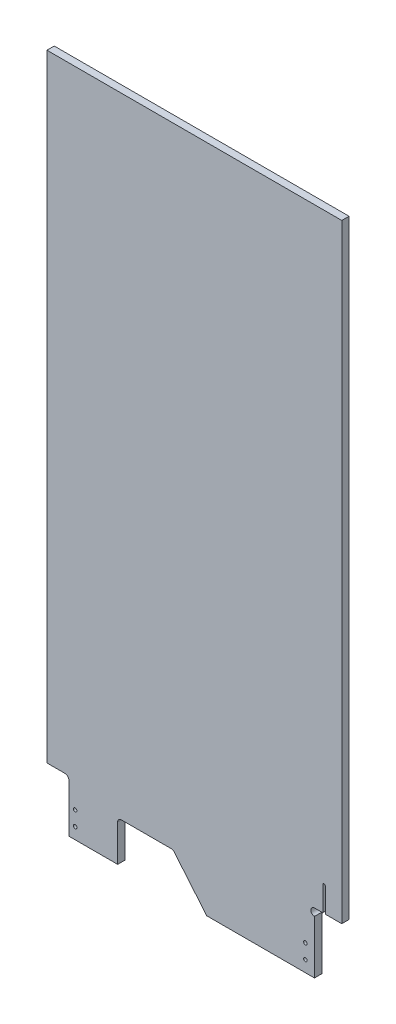
from build123d import *

# Parameters (mm, degrees)
EXTRUDE1_DEPTH     = 12.7
SKETCH3_R          = 3.1115
CUT_EXTRUDE1_DEPTH = 12.7


with BuildPart() as part:
    # Sketch2 → Extrude1 (new body)
    with BuildSketch(Plane.XY):
        with BuildLine():
            Line((10375.902142089, 13017.500110193), (10375.902142089, 13102.653009206))
            ThreePointArc((10375.902142089, 13102.653009206), (10374.042270149, 13107.143137266), (10369.552142089, 13109.003009206))
            Line((10369.552142089, 13109.003009206), (10337.802142089, 13109.003009206))
            Line((10337.802142089, 13109.003009206), (10337.800747814, 14185.900110193))
            Line((10337.800747814, 14185.900110193), (10852.147924282, 14185.900110193))
            Line((10852.147924282, 14185.900110193), (10852.150747814, 13123.290509206))
            Line((10852.150747814, 13123.290509206), (10823.581236416, 13123.290509206))
            Line((10823.581236416, 13123.290509206), (10823.581236416, 13165.835509206))
            ThreePointArc((10823.581236416, 13165.835509206), (10821.295236416, 13168.121509206), (10819.009236416, 13165.835509206))
            Line((10819.009236416, 13165.835509206), (10819.009236416, 13123.290509206))
            Line((10819.009236416, 13123.290509206), (10804.525747814, 13123.290509206))
            ThreePointArc((10804.525747814, 13123.290509206), (10798.175747814, 13116.940509206), (10804.525747814, 13110.590509206))
            Line((10804.525747814, 13110.590509206), (10804.525747814, 13017.500110193))
            Line((10804.525747814, 13017.500110193), (10616.625223517, 13017.500110193))
            Line((10616.625223517, 13017.500110193), (10559.649893716, 13085.667043341))
            ThreePointArc((10559.649893716, 13085.667043341), (10557.466824452, 13087.347190416), (10554.77765388, 13087.944724716))
            Line((10554.77765388, 13087.944724716), (10467.552782059, 13087.944724716))
            ThreePointArc((10467.552782059, 13087.944724716), (10463.062653998, 13086.084852777), (10461.202782059, 13081.594724716))
            Line((10461.202782059, 13081.594724716), (10461.202782059, 13017.500110193))
            Line((10461.202782059, 13017.500110193), (10375.902142089, 13017.500110193))
        make_face()
    extrude(amount=-EXTRUDE1_DEPTH)

    # Sketch3 → Cut-Extrude1 (cut)
    with BuildSketch(Plane.XY):
        with Locations((10387.012550678, 13062.712110193)):
            Circle(SKETCH3_R)
        with Locations((10387.012550678, 13037.312110193)):
            Circle(SKETCH3_R)
        with Locations((10788.650050678, 13062.712110193)):
            Circle(SKETCH3_R)
        with Locations((10788.650050678, 13037.312110193)):
            Circle(SKETCH3_R)
    extrude(amount=-CUT_EXTRUDE1_DEPTH, mode=Mode.SUBTRACT)


solid = part.part
